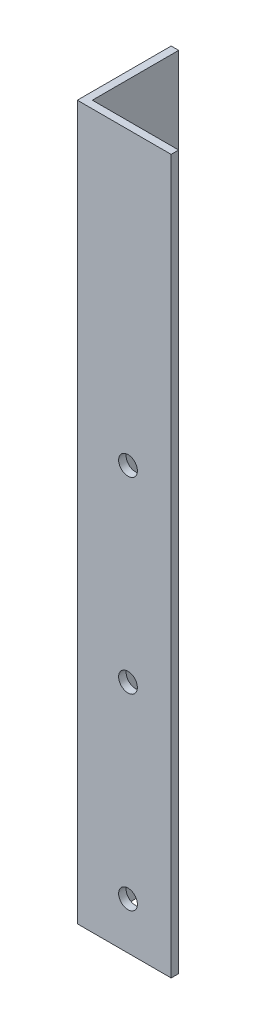
from build123d import *

# Parameters (mm, degrees)
EXTRUDE_1_DEPTH     = 380
SKETCH_2_R          = 5
CUT_EXTRUDE_1_DEPTH = 10
SKETCH_3_R          = 5
CUT_EXTRUDE_2_DEPTH = 10


with BuildPart() as part:
    # Эскиз1 → Вытянуть-Тонкостенный1 (new body)
    with BuildSketch(Plane(origin=(0, 0, 0), x_dir=(1, 0, 0), z_dir=(0, 1, 0))):
        Polygon((0, 50), (0, 0), (50, 0), (50, 4), (4, 4), (4, 50), align=None)
    extrude(amount=EXTRUDE_1_DEPTH)

    # Эскиз2 → Вырез-Вытянуть1 (cut)
    with BuildSketch(Plane.XY):
        with Locations((27, 225)):
            Circle(SKETCH_2_R)
        with Locations((27, 125)):
            Circle(SKETCH_2_R)
        with Locations((27, 25)):
            Circle(SKETCH_2_R)
    extrude(amount=-CUT_EXTRUDE_1_DEPTH, mode=Mode.SUBTRACT)

    # Эскиз3 → Вырез-Вытянуть2 (cut)
    with BuildSketch(Plane.ZY):
        with Locations((-23, 225)):
            Circle(SKETCH_3_R)
        with Locations((-23, 125)):
            Circle(SKETCH_3_R)
        with Locations((-23, 25)):
            Circle(SKETCH_3_R)
    extrude(amount=-CUT_EXTRUDE_2_DEPTH, mode=Mode.SUBTRACT)


solid = part.part
